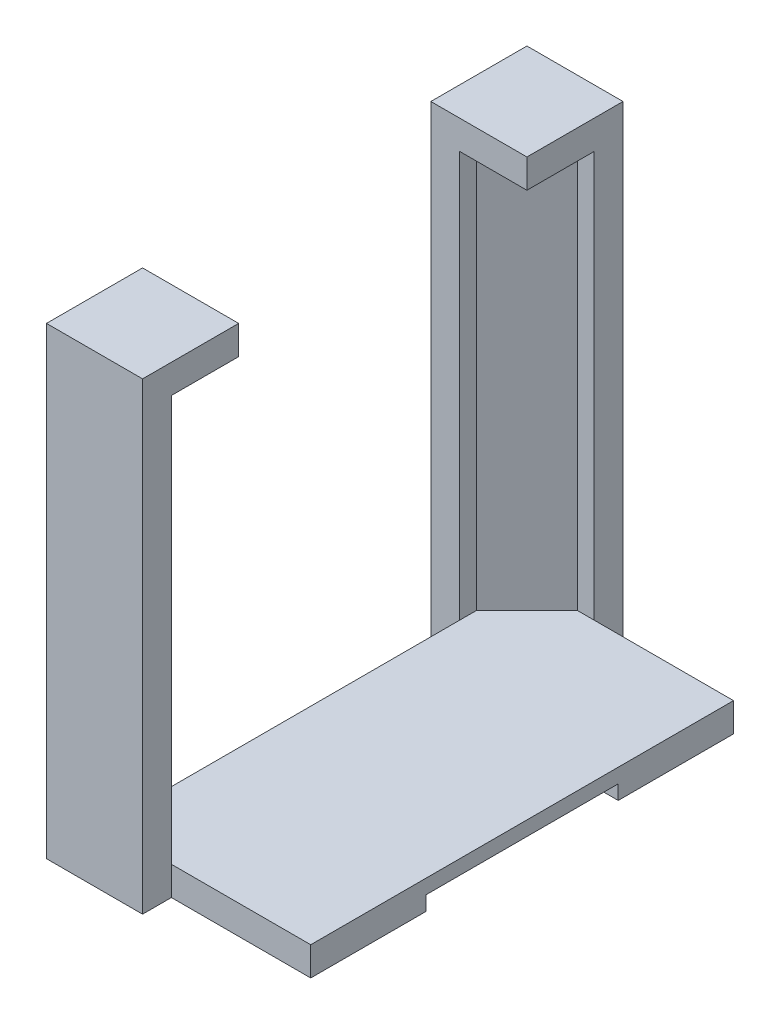
from build123d import *

# Parameters (mm, degrees)
SKETCH1_W           = 21.5
SKETCH1_H           = 44
BOSS_EXTRUDE2_DEPTH = 3
SKETCH1_8_W         = 10
SKETCH1_8_H         = 20
CUT_EXTRUDE1_DEPTH  = 1.5
BOSS_EXTRUDE3_DEPTH = 45.25
SKETCH2_W           = 10
SKETCH2_H           = 10
BOSS_EXTRUDE4_DEPTH = 3
CHAMFER4_SIZE       = 5.25


with BuildPart() as part:
    # Sketch1 → Boss-Extrude2 (new body)
    with BuildSketch(Plane(origin=(0, 0, 0), x_dir=(1, 0, 0), z_dir=(0, 1, 0))):
        with Locations((-10.75, 22)):
            Rectangle(SKETCH1_W, SKETCH1_H)
    extrude(amount=BOSS_EXTRUDE2_DEPTH)

    # Sketch1_8 → Cut-Extrude1 (cut)
    with BuildSketch(Plane(origin=(0, 0, 0), x_dir=(1, 0, 0), z_dir=(0, 1, 0))):
        with Locations((-5, 22)):
            Rectangle(SKETCH1_8_W, SKETCH1_8_H)
    extrude(amount=CUT_EXTRUDE1_DEPTH, mode=Mode.SUBTRACT)

    # Sketch1_9 → Boss-Extrude3 (add)
    with BuildSketch(Plane(origin=(0, 0, 0), x_dir=(1, 0, 0), z_dir=(0, 1, 0))):
        Polygon((-24.5, 37), (-21.5, 37), (-21.5, 44), (-14.5, 44), (-14.5, 47), (-24.5, 47), align=None)
        Polygon((-21.5, 0), (-21.5, 7), (-24.5, 7), (-24.5, -3), (-14.5, -3), (-14.5, 0), align=None)
    extrude(amount=BOSS_EXTRUDE3_DEPTH)

    # Sketch2 → Boss-Extrude4 (add)
    with BuildSketch(Plane(origin=(0, 45.25, 0), x_dir=(1, 0, 0), z_dir=(0, 1, 0))):
        with Locations((-19.5, 2)):
            Rectangle(SKETCH2_W, SKETCH2_H)
        with Locations((-19.5, 42)):
            Rectangle(SKETCH2_W, SKETCH2_H)
    extrude(amount=BOSS_EXTRUDE4_DEPTH)

    # Chamfer4
    chamfer4_edges = [part.edges().sort_by_distance(p)[0] for p in [
        (-21.5, 24.125, 0),
        (-21.5, 24.125, -44),
    ]]
    chamfer(chamfer4_edges, length=CHAMFER4_SIZE)


solid = part.part
